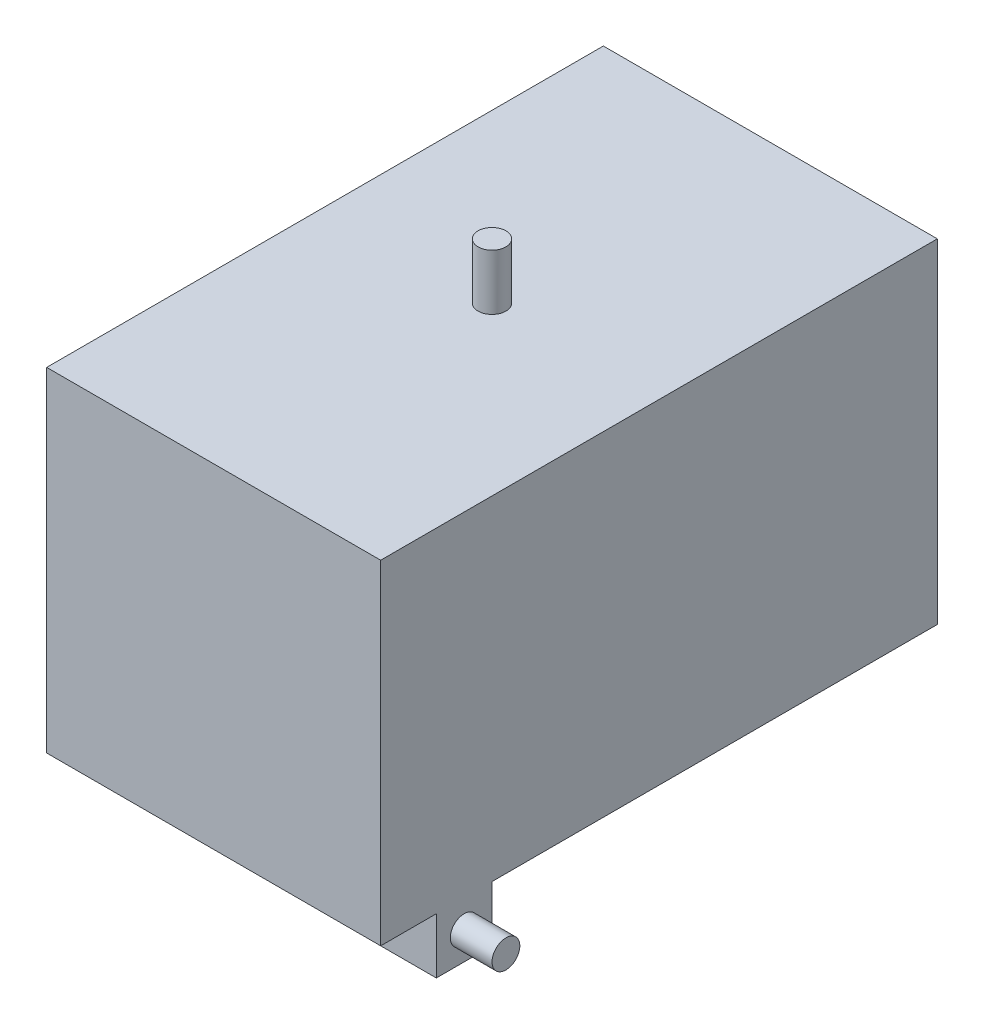
from build123d import *

# Parameters (mm, degrees)
SKETCH1_W             = 152.4
SKETCH1_H             = 152.4
SKETCH1_W_2           = 146.05
SKETCH1_H_2           = 146.05
BOSS_EXTRUDE1_DEPTH   = 127
SKETCH2_W             = 146.05
SKETCH2_H             = 146.05
BOSS_EXTRUDE2_DEPTH   = 3.175
SKETCH3_W             = 146.05
SKETCH3_H             = 146.05
BOSS_EXTRUDE3_DEPTH   = 3.175
SKETCH4_W             = 50.8
SKETCH4_H             = 25.4
BOSS_EXTRUDE4_DEPTH   = 25.4
BOSS_EXTRUDE4_2_DEPTH = 25.4
SKETCH7_R             = 6.35
BOSS_EXTRUDE5_DEPTH   = 25.4
SKETCH8_R             = 6.35
BOSS_EXTRUDE6_DEPTH   = 19.05
SKETCH9_R             = 6.35
BOSS_EXTRUDE7_DEPTH   = 19.05


with BuildPart() as part:
    # Sketch1 → Boss-Extrude1 (new, symmetric)
    with BuildSketch(Plane.XY):
        Rectangle(SKETCH1_W, SKETCH1_H)
        Rectangle(SKETCH1_W_2, SKETCH1_H_2, mode=Mode.SUBTRACT)
    extrude(amount=BOSS_EXTRUDE1_DEPTH, both=True)

    # Sketch2 → Boss-Extrude2 (add)
    with BuildSketch(Plane.XY.offset(127)):
        Rectangle(SKETCH2_W, SKETCH2_H)
    extrude(amount=-BOSS_EXTRUDE2_DEPTH)

    # Sketch3 → Boss-Extrude3 (add)
    with BuildSketch(Plane(origin=(0, 0, -127), x_dir=(-1, 0, 0), z_dir=(0, 0, -1))):
        Rectangle(SKETCH3_W, SKETCH3_H)
    extrude(amount=-BOSS_EXTRUDE3_DEPTH)

    # Sketch6 → Revolve2 (revolve)
    with BuildSketch(Plane(origin=(0, 0, -101.6), x_dir=(-1, 0, 0), z_dir=(0, 0, -1))):
        with BuildLine():
            Line((0, -76.2), (0, -127))
            ThreePointArc((0, -127), (17.960512242, -119.560512242), (25.4, -101.6))
            Line((25.4, -101.6), (9.525, -101.6))
            Line((9.525, -101.6), (9.525, -76.2))
            Line((9.525, -76.2), (0, -76.2))
        make_face()
    revolve(axis=Axis((0, -76.2, -101.6), (0, -1, 0)))

    # Sketch7 → Boss-Extrude5 (add)
    with BuildSketch(Plane(origin=(0, 76.2, 0), x_dir=(1, 0, 0), z_dir=(0, 1, 0))):
        with Locations(Location((0, 0, 0), (0, 0, 90))):
            Circle(SKETCH7_R)
    extrude(amount=BOSS_EXTRUDE5_DEPTH)


with BuildPart() as body_2:
    # Sketch4 → Boss-Extrude4 (new body)
    with BuildSketch(Plane.XZ.offset(76.2)):
        with Locations((50.8, 88.9)):
            Rectangle(SKETCH4_W, SKETCH4_H)
    extrude(amount=BOSS_EXTRUDE4_DEPTH)


    add(part.part)  # Boss-Extrude6 merges part
    # Sketch8 → Boss-Extrude6 (add)
    with BuildSketch(Plane(origin=(76.2, 0, 0), x_dir=(0, 0, -1), z_dir=(1, 0, 0))):
        with Locations(Location((-88.9, -88.9, 0), (0, 0, 180))):
            Circle(SKETCH8_R)
    extrude(amount=BOSS_EXTRUDE6_DEPTH)


with BuildPart() as body_3:
    # Sketch4 → Boss-Extrude4 2 (new body)
    with BuildSketch(Plane.XZ.offset(76.2)):
        with Locations((-50.8, 88.9)):
            Rectangle(SKETCH4_W, SKETCH4_H)
    extrude(amount=BOSS_EXTRUDE4_2_DEPTH)


    add(body_2.part)  # Boss-Extrude7 merges body 2
    # Sketch9 → Boss-Extrude7 (add)
    with BuildSketch(Plane.ZY.offset(76.2)):
        with Locations(Location((88.9, -88.9, 0), (0, 0, 180))):
            Circle(SKETCH9_R)
    extrude(amount=BOSS_EXTRUDE7_DEPTH)


solid = body_3.part
